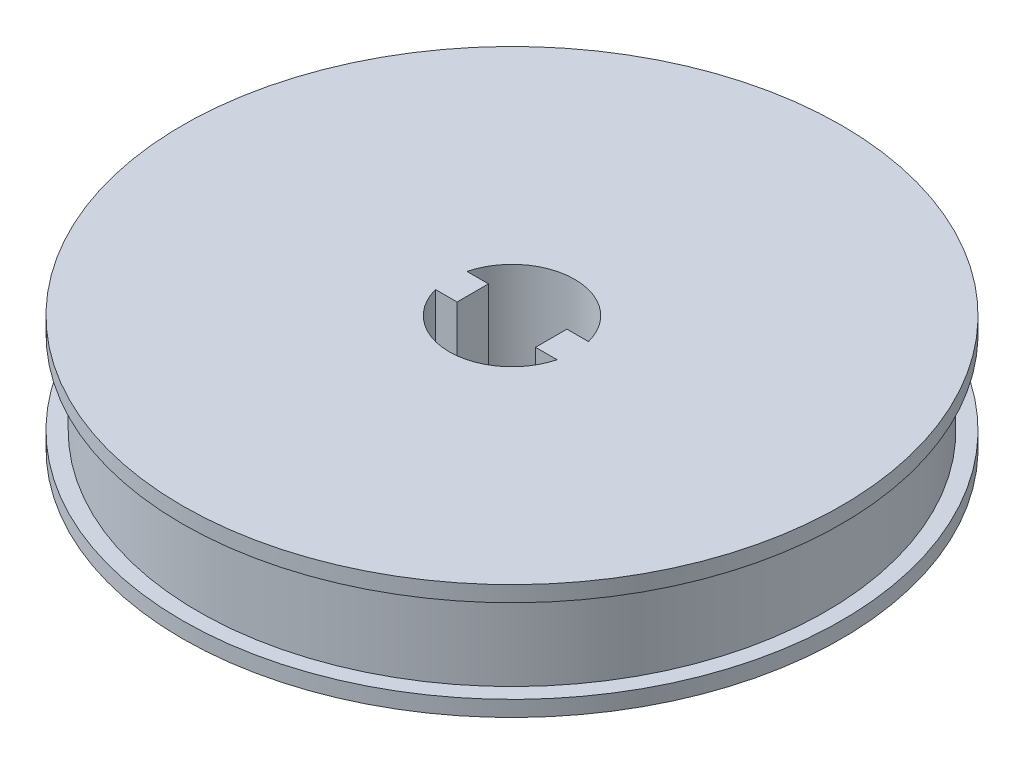
from build123d import *

# Parameters (mm, degrees)
ESQUISSE6_W        = 4.5
ESQUISSE6_H        = 3
BOSS_EXTRU_1_DEPTH = 11


with BuildPart() as part:
    # Esquisse2 → Révolution1 (revolve)
    with BuildSketch(Plane.XY):
        Polygon((6, 5.365286165), (6, -5.634713835), (31.5, -5.634713835), (31.5, -4.134713835), (30, -4.134713835), (30, 3.865286165), (31.5, 3.865286165), (31.5, 5.365286165), align=None)
    revolve(axis=Axis((0, 0, 0), (0, 1, 0)))

    # Esquisse6 → Boss.-Extru.1 (add)
    with BuildSketch(Plane(origin=(0, 5.365286165, 0), x_dir=(1, 0, 0), z_dir=(0, 1, 0))):
        with Locations((-6, 0)):
            Rectangle(ESQUISSE6_W, ESQUISSE6_H)
        with Locations((6, 0)):
            Rectangle(ESQUISSE6_W, ESQUISSE6_H)
    extrude(amount=-BOSS_EXTRU_1_DEPTH)


solid = part.part
